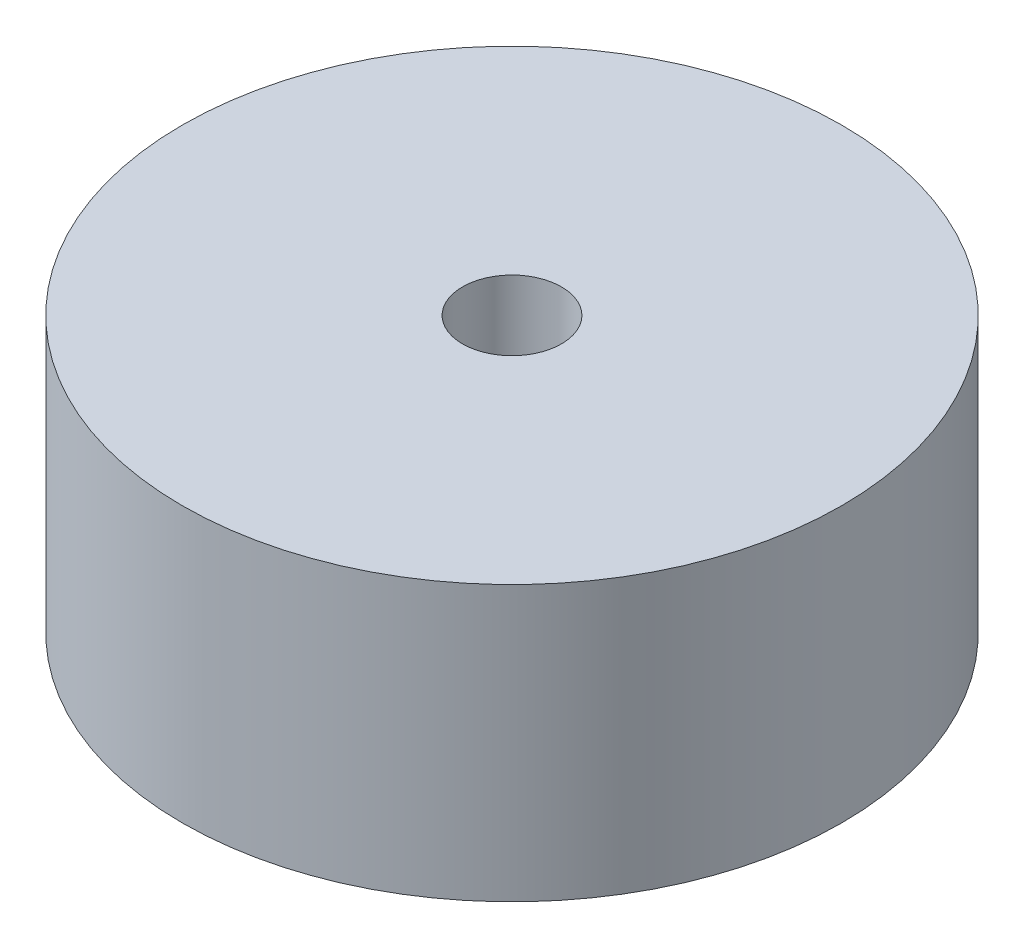
from build123d import *

# Parameters (mm, degrees)
SKETCH1_R           = 60
SKETCH1_R_2         = 9
BOSS_EXTRUDE1_DEPTH = 50


with BuildPart() as part:
    # Sketch1 → Boss-Extrude1 (new body)
    with BuildSketch(Plane(origin=(0, 0, 0), x_dir=(1, 0, 0), z_dir=(0, 1, 0))):
        Circle(SKETCH1_R)
        Circle(SKETCH1_R_2, mode=Mode.SUBTRACT)
    extrude(amount=BOSS_EXTRUDE1_DEPTH)


solid = part.part
